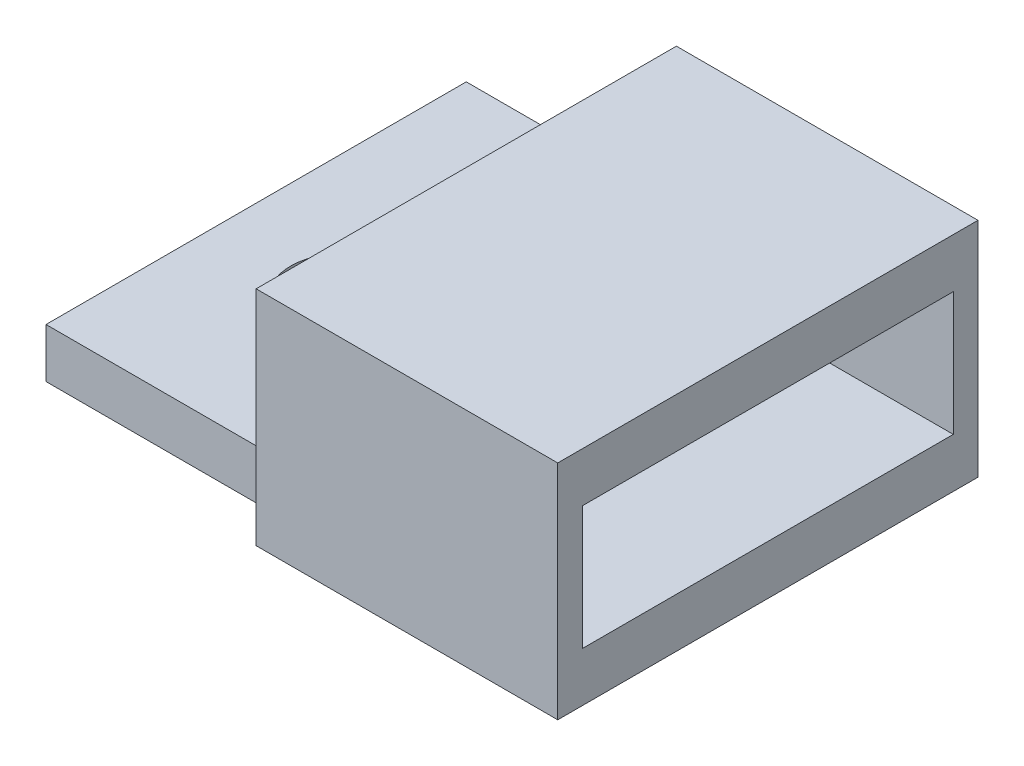
from build123d import *

# Parameters (mm, degrees)
SKETCH1_W           = 10
SKETCH1_H           = 14
SKETCH1_R           = 2.1
BOSS_EXTRUDE1_DEPTH = 2
SKETCH2_W           = 1.8
SKETCH2_H           = 13.4
BOSS_EXTRUDE2_DEPTH = 5
SKETCH3_W           = 1.8
SKETCH3_H           = 1.8
CUT_EXTRUDE1_DEPTH  = 9
SKETCH5_W           = 12.2
SKETCH5_H           = 17
BOSS_EXTRUDE4_DEPTH = 2
SKETCH6_W           = 14
SKETCH6_H           = 5
SKETCH6_W_2         = 0.5
CUT_EXTRUDE2_DEPTH  = 14
SKETCH7_W           = 10
SKETCH7_H           = 2
BOSS_EXTRUDE5_DEPTH = 3


with BuildPart() as part:
    # Sketch1 → Boss-Extrude1 (new body)
    with BuildSketch(Plane(origin=(0, 0, 0), x_dir=(1, 0, 0), z_dir=(0, 1, 0))):
        Rectangle(SKETCH1_W, SKETCH1_H)
        Circle(SKETCH1_R, mode=Mode.SUBTRACT)
        Polygon((5, 7), (5, -7), (5, -8.5), (19, -8.5), (19, 8.5), (5, 8.5), align=None)
    extrude(amount=BOSS_EXTRUDE1_DEPTH)

    # Sketch2 → Boss-Extrude2 (add)
    with BuildSketch(Plane(origin=(0, 2, 0), x_dir=(1, 0, 0), z_dir=(0, 1, 0))):
        Polygon((17.2, 6.7), (19, 6.7), (19, 8.5), (5, 8.5), (5, 7), (5, 6.7), align=None)
        with Locations((18.1, 0)):
            Rectangle(SKETCH2_W, SKETCH2_H)
        Polygon((5, -7), (5, -8.5), (19, -8.5), (19, -6.7), (17.2, -6.7), (5, -6.7), align=None)
    extrude(amount=BOSS_EXTRUDE2_DEPTH)

    # Sketch3 → Cut-Extrude1 (cut)
    with BuildSketch(Plane(origin=(0, 7, 0), x_dir=(1, 0, 0), z_dir=(0, 1, 0))):
        Polygon((19, -6.7), (19, 8.5), (17.2, 8.5), (17.2, 6.7), (17.2, -6.7), align=None)
        with Locations((18.1, -7.6)):
            Rectangle(SKETCH3_W, SKETCH3_H)
    extrude(amount=-CUT_EXTRUDE1_DEPTH, mode=Mode.SUBTRACT)

    # Sketch5 → Boss-Extrude4 (add)
    with BuildSketch(Plane(origin=(0, 7, 0), x_dir=(1, 0, 0), z_dir=(0, 1, 0))):
        with Locations((11.1, 0)):
            Rectangle(SKETCH5_W, SKETCH5_H)
    extrude(amount=BOSS_EXTRUDE4_DEPTH)

    # Sketch6 → Cut-Extrude2 (cut)
    with BuildSketch(Plane.ZY.offset(-5)):
        with Locations((0, 4.5)):
            Rectangle(SKETCH6_W, SKETCH6_H)
        with Locations((-7.25, 4.5)):
            Rectangle(SKETCH6_W_2, SKETCH6_H)
        with Locations((7.25, 4.5)):
            Rectangle(SKETCH6_W_2, SKETCH6_H)
    extrude(amount=-CUT_EXTRUDE2_DEPTH, mode=Mode.SUBTRACT)

    # Sketch7 → Boss-Extrude5 (add)
    with BuildSketch(Plane(origin=(0, 0, -7), x_dir=(-1, 0, 0), z_dir=(0, 0, -1))):
        with Locations((0, 1)):
            Rectangle(SKETCH7_W, SKETCH7_H)
    extrude(amount=BOSS_EXTRUDE5_DEPTH)


solid = part.part
